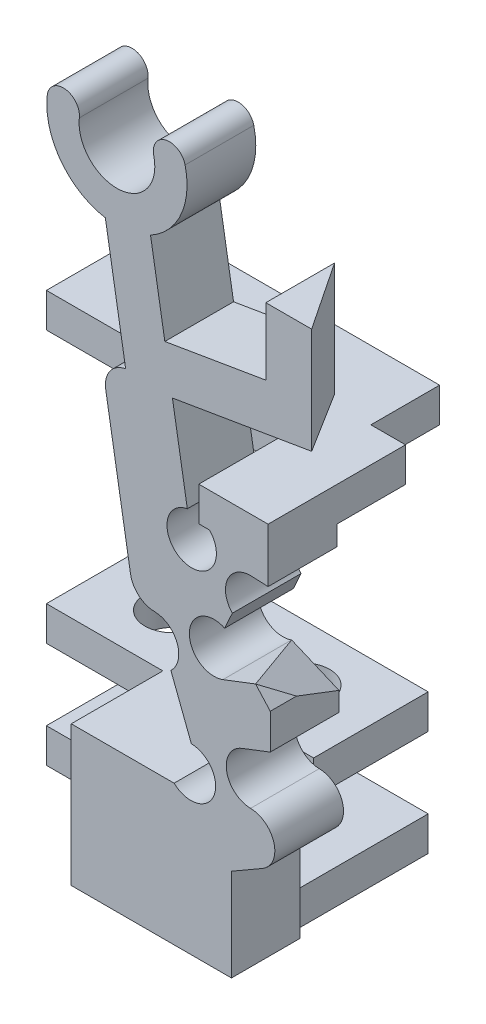
from build123d import *

# Parameters (mm, degrees)
BOSS_SWITCHMAIN_DEPTH           = 3
SKETCH1_W                       = 6.582729781
SKETCH1_H                       = 1.5
SKETCH1_W_2                     = 3.025930853
SKETCH1_W_3                     = 4.49100728
BOSS_FLANGE_WIDTH_DEPTH         = 6
SKETCH2_W                       = 5
SKETCH2_H                       = 1.5
BOSS_FLANGE_HEIGHT_DEPTH        = 11.6675
TAP_DRILL_FOR_M2X0_4_TAP1_D     = 1.6
M2_CLEARANCE_HOLE2_D            = 2.4
M2_CLEARANCE_HOLE2_DEPTH        = 6.113984988
M2_CLEARANCE_HOLE2_TIP          = 0.721032743
CUT_FLANGE_RAMP_CLEARANCE_REACH = 19.959
SKETCH10_W                      = 1.51157113
SKETCH10_H                      = 3
CUT_EXTRUDE1_REACH              = 28.283
CUT_EXTRUDE2_REACH              = 22.07


with BuildPart() as part:
    # Sketch-SwitchBossUp → Boss-SwitchMain (new body)
    with BuildSketch(Plane.XY):
        with BuildLine():
            Line((6.540476927, 22.165014537), (6.540476927, 25.093856925))
            Line((6.540476927, 25.093856925), (8.540476927, 25.093856925))
            Line((8.540476927, 25.093856925), (8.540476927, 20.473554675))
            Line((8.540476927, 20.473554675), (2.463355023, 19.450530066))
            Line((2.463355023, 19.450530066), (3.113617204, 15.587746603))
            ThreePointArc((3.113617204, 15.587746603), (2.228151344, 14.454516392), (3.25659329, 13.449246446))
            ThreePointArc((3.25659329, 13.449246446), (4.285298124, 14.079636296), (4.085366752, 15.269448233))
            Line((4.085366752, 15.269448233), (3.613617204, 15.269448233))
            Line((3.613617204, 15.269448233), (3.613617204, 16.769448233))
            Line((3.613617204, 16.769448233), (6.639548057, 16.769448233))
            Line((6.639548057, 16.769448233), (6.639548057, 14.40837951))
            Line((6.639548057, 14.40837951), (5.90556854, 14.440674771))
            ThreePointArc((5.90556854, 14.440674771), (4.876863705, 13.810284921), (5.076795077, 12.620472983))
            Line((5.076795077, 12.620472983), (4.742765687, 11.886857682))
            ThreePointArc((4.742765687, 11.886857682), (4.116092357, 11.977881728), (3.546393548, 11.701389219))
            ThreePointArc((3.546393548, 11.701389219), (3.274676841, 10.525891439), (4.263259905, 9.834278449))
            ThreePointArc((4.263259905, 9.834278449), (4.46894162, 9.850585257), (4.667751547, 9.905771245))
            Line((4.667751547, 9.905771245), (6.093996382, 10.453369682))
            Line((6.093996382, 10.453369682), (6.73413388, 9.742424966))
            Line((6.73413388, 9.742424966), (6.73413388, 8.198043394))
            Line((6.73413388, 8.198043394), (6.493366278, 8.105602069))
            Line((6.493366278, 8.105602069), (5.504663813, 7.725995489))
            ThreePointArc((5.504663813, 7.725995489), (5.320005472, 7.633951058), (5.156260325, 7.508418563))
            ThreePointArc((5.156260325, 7.508418563), (4.884543619, 6.332920783), (5.873126682, 5.641307794))
            ThreePointArc((5.873126682, 5.641307794), (6.898907846, 4.833576465), (6.394232666, 3.629433676))
            Line((6.394232666, 3.629433676), (5.040476927, 2.847842436))
            Line((5.040476927, 2.847842436), (5.040476927, -1.189543551))
            Line((5.040476927, -1.189543551), (-1.954752854, -1.189543551))
            Line((-1.954752854, -1.189543551), (-1.954752854, 4.924441437))
            Line((-1.954752854, 4.924441437), (2.536254426, 4.924441437))
            ThreePointArc((2.536254426, 4.924441437), (3.271135169, 4.635221221), (4.006015912, 4.924441437))
            ThreePointArc((4.006015912, 4.924441437), (4.277732619, 6.099939217), (3.289149555, 6.791552207))
            Line((3.289149555, 6.791552207), (2.396149135, 9.117412093))
            ThreePointArc((2.396149135, 9.117412093), (2.667865841, 10.292909873), (1.679282778, 10.984522862))
            ThreePointArc((1.679282778, 10.984522862), (0.990609652, 11.24824473), (0.632497087, 11.892896022))
            Line((0.632497087, 11.892896022), (-0.448028681, 18.3115948))
            ThreePointArc((-0.448028681, 18.3115948), (-0.266285833, 19.102309392), (0.421345416, 19.532917442))
            Line((0.421345416, 19.532917442), (-0.465233701, 24.799505683))
            ThreePointArc((-0.465233701, 24.799505683), (-2.406587703, 25.978955839), (-3.001107523, 28.171329943))
            ThreePointArc((-3.001107523, 28.171329943), (-2.220760115, 28.789797628), (-1.602292431, 28.009450221))
            ThreePointArc((-1.602292431, 28.009450221), (0.141134159, 26.168671513), (1.647974165, 28.207650602))
            ThreePointArc((1.647974165, 28.207650602), (2.167041147, 29.057364566), (3.016755111, 28.538297585))
            ThreePointArc((3.016755111, 28.538297585), (2.839798095, 26.578800421), (1.507016259, 25.131514861))
            Line((1.507016259, 25.131514861), (2.131345845, 21.422780026))
            Line((2.131345845, 21.422780026), (6.540476927, 22.165014537))
        make_face()
    extrude(amount=BOSS_SWITCHMAIN_DEPTH)

    # Sketch1 → Boss-Flange Width (add)
    with BuildSketch(Plane(origin=(0, 0, 0), x_dir=(-1, 0, 0), z_dir=(0, 0, -1))):
        with Locations((-1.336612037, -0.439543551)):
            Rectangle(SKETCH1_W, SKETCH1_H)
        with Locations((-5.126582631, 16.019448233)):
            Rectangle(SKETCH1_W_2, SKETCH1_H)
        with Locations((-0.290750786, 4.174441437)):
            Rectangle(SKETCH1_W_3, SKETCH1_H)
    extrude(amount=BOSS_FLANGE_WIDTH_DEPTH)

    # Sketch2 → Boss-Flange Height (add)
    with BuildSketch(Plane(origin=(-7.039523073, 0, 0), x_dir=(0, 0, -1), z_dir=(1, 0, 0))):
        with Locations((3.5, 16.019448233)):
            Rectangle(SKETCH2_W, SKETCH2_H)
        with Locations((3.5, 4.174441437)):
            Rectangle(SKETCH2_W, SKETCH2_H)
        with Locations((3.5, -0.439543551)):
            Rectangle(SKETCH2_W, SKETCH2_H)
    extrude(amount=BOSS_FLANGE_HEIGHT_DEPTH)

    # Tap Drill for M2x0.4 Tap1 (through all)
    with Locations(Plane(origin=(0, -1.189543551, 0), x_dir=(-1, 0, 0), z_dir=(0, -1, 0))):
        with Locations((4.039523073, 3.5), (-1.627976927, 3.5)):
            Hole(TAP_DRILL_FOR_M2X0_4_TAP1_D / 2)

    # M2 Clearance Hole2
    with Locations(Plane.XZ.offset(1.189543551)):
        with Locations((-4.039523073, -3.5), (1.627976927, -3.5)):
            Hole(M2_CLEARANCE_HOLE2_D / 2, depth=M2_CLEARANCE_HOLE2_DEPTH)
            with Locations((0, 0, -(M2_CLEARANCE_HOLE2_DEPTH + M2_CLEARANCE_HOLE2_TIP / 2))):  # 118° drill point
                Cone(0, M2_CLEARANCE_HOLE2_D / 2, M2_CLEARANCE_HOLE2_TIP, mode=Mode.SUBTRACT)

    # Sketch10 → Cut-Flange Ramp Clearance (cut, up to next)
    with BuildSketch(Plane(origin=(0, 16.769448233, 0), x_dir=(1, 0, 0), z_dir=(0, 1, 0)), mode=Mode.PRIVATE) as cut_flange_ramp_clearance_sk1:
        with Locations((5.883762492, 4.5)):
            Rectangle(SKETCH10_W, SKETCH10_H)
    cut_flange_ramp_clearance_tool1 = extrude(cut_flange_ramp_clearance_sk1.sketch, amount=-CUT_FLANGE_RAMP_CLEARANCE_REACH, mode=Mode.PRIVATE) & part.part
    add(cut_flange_ramp_clearance_tool1.solids().sort_by_distance((5.883762, 16.769448, -4.5))[0], mode=Mode.SUBTRACT)

    # Sketch12 → Cut-Extrude1 (cut, up to next)
    with BuildSketch(Plane(origin=(0, 25.093856925, 0), x_dir=(1, 0, 0), z_dir=(0, 1, 0)), mode=Mode.PRIVATE) as cut_extrude1_sk1:
        Polygon((6.540476927, 0), (8.540476927, -3), (8.540476927, 0), align=None)
    cut_extrude1_tool1 = extrude(cut_extrude1_sk1.sketch, amount=-CUT_EXTRUDE1_REACH, mode=Mode.PRIVATE) & part.part
    add(cut_extrude1_tool1.solids().sort_by_distance((7.87381, 25.093857, 1))[0], mode=Mode.SUBTRACT)

    # Sketch14 → Cut-Extrude2 (cut, up to next)
    with BuildSketch(Plane(origin=(3.789105765, 8.959047136, -3.436717579), x_dir=(-0.930109907, 0.342916579, -0.131543837), z_dir=(-0.367281311, -0.868408215, 0.333124018)), mode=Mode.PRIVATE) as cut_extrude2_sk1:
        Polygon((-0.94466877, -3.547806869), (-4.277307049, -3.078270724), (-4.824829049, -6.964431121), (-1.431952972, -6.964431121), align=None)
    cut_extrude2_tool1 = extrude(cut_extrude2_sk1.sketch, amount=-CUT_EXTRUDE2_REACH, mode=Mode.PRIVATE) & part.part
    add(cut_extrude2_tool1.solids().sort_by_distance((6.491643, 9.802029, 1.740466))[0], mode=Mode.SUBTRACT)


solid = part.part
